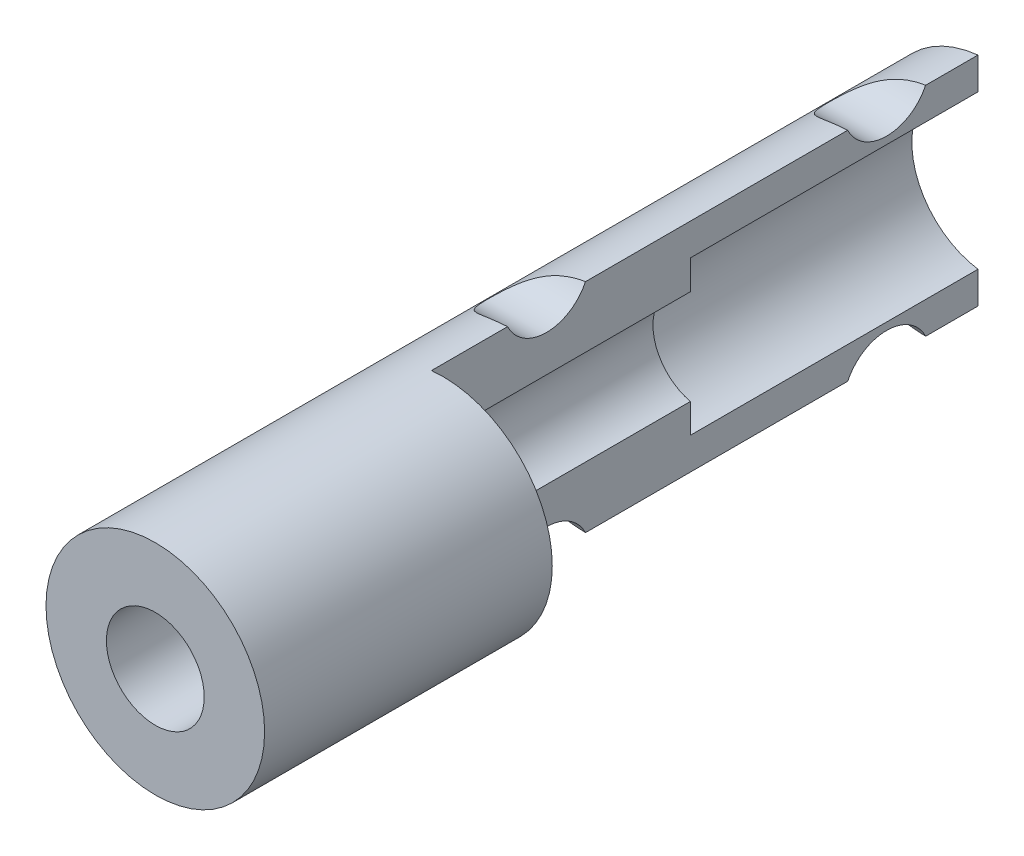
from build123d import *

# Parameters (mm, degrees)
SKETCH1_R      = 3.8
SKETCH1_R_2    = 1.7
EXTRUDE1_DEPTH = 10
EXTRUDE2_DEPTH = 9
EXTRUDE3_DEPTH = 10
SKETCH4_R      = 1.5
EXTRUDE4_DEPTH = 17
SKETCH5_W      = 0.4
SKETCH5_H      = 9.525
EXTRUDE5_DEPTH = 19


with BuildPart() as part:
    # Sketch1 → Extrude1 (new body)
    with BuildSketch(Plane.XY):
        Circle(SKETCH1_R)
        Circle(SKETCH1_R_2, mode=Mode.SUBTRACT)
    extrude(amount=EXTRUDE1_DEPTH)

    # Sketch2 → Extrude2 (add)
    with BuildSketch(Plane(origin=(0, 0, 0), x_dir=(-1, 0, 0), z_dir=(0, 0, -1))):
        with BuildLine():
            Line((0, 3.8), (0, 1.7))
            ThreePointArc((0, 1.7), (1.7, 0), (0, -1.7))
            Line((0, -1.7), (0, -3.8))
            ThreePointArc((0, -3.8), (3.8, 0), (0, 3.8))
        make_face()
    extrude(amount=EXTRUDE2_DEPTH)

    # Sketch3 → Extrude3 (add)
    with BuildSketch(Plane(origin=(0, 0, -9), x_dir=(-1, 0, 0), z_dir=(0, 0, -1))):
        with BuildLine():
            Line((0, 3.8), (0, 2.7))
            ThreePointArc((0, 2.7), (2.7, 0), (0, -2.7))
            Line((0, -2.7), (0, -3.8))
            ThreePointArc((0, -3.8), (3.8, 0), (0, 3.8))
        make_face()
    extrude(amount=EXTRUDE3_DEPTH)

    # Sketch4 → Extrude4 (cut)
    with BuildSketch(Plane(origin=(0, 0, 0), x_dir=(0, 0, -1), z_dir=(1, 0, 0))):
        with Locations((4, 4.425)):
            Circle(SKETCH4_R)
        with Locations((15.825, 4.425)):
            Circle(SKETCH4_R)
        with Locations((15.825, -4.425)):
            Circle(SKETCH4_R)
        with Locations((4, -4.425)):
            Circle(SKETCH4_R)
    extrude(amount=-EXTRUDE4_DEPTH, mode=Mode.SUBTRACT)

    # Sketch5 → Extrude5 (cut)
    with BuildSketch(Plane(origin=(0, 0, -19), x_dir=(-1, 0, 0), z_dir=(0, 0, -1))):
        with Locations((0.2, 0)):
            Rectangle(SKETCH5_W, SKETCH5_H)
    extrude(amount=-EXTRUDE5_DEPTH, mode=Mode.SUBTRACT)


solid = part.part
